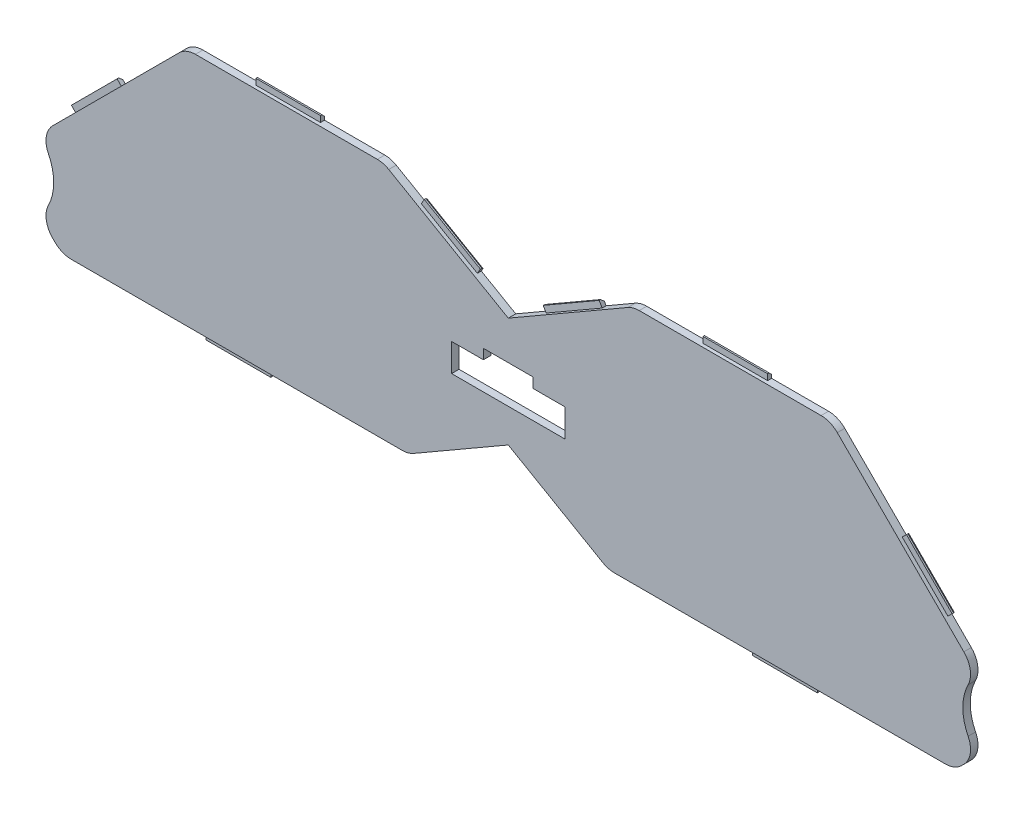
from build123d import *

# Parameters (mm, degrees)
BOSS_EXTRUDE1_DEPTH      = 1.5
SKETCH5_W                = 13
SKETCH5_H                = 1.2
BOSS_EXTRUDE2_DEPTH      = 0.8
CHAMFER1_SIZE            = 0.5
SKETCH6_R                = 10
CUT_EXTRUDE3_DEPTH       = 1.5
CHAMFER1_OF_MIRROR1_SIZE = 0.5
CUT_EXTRUDE1_REACH       = 3.5
FILLET1_R                = 4.6


with BuildPart() as part:
    # Sketch1 → Boss-Extrude1 (new body)
    with BuildSketch(Plane.XY):
        Polygon((0, 22.557357671), (25.107179677, 37.052994616), (64.834314575, 37.052994616), (101.434314575, 0.452994616), (89.834314575, -11.147005384), (20.107179677, -11.147005384), (0, 0.461880215), align=None)
    boss_extrude1 = extrude(amount=BOSS_EXTRUDE1_DEPTH)

    # Sketch5 → Boss-Extrude2 (add)
    with BuildSketch(Plane(origin=(0, 0, 0), x_dir=(-1, 0, 0), z_dir=(0, 0, -1))):
        with Locations((-44.970747126, 37.652994616)):
            Rectangle(SKETCH5_W, SKETCH5_H)
        with Locations((-54.970747126, -11.747005384)):
            Rectangle(SKETCH5_W, SKETCH5_H)
        Polygon((-78.538120497, 23.349188694), (-87.730508653, 14.156800538), (-88.57903679, 15.005328676), (-79.386648635, 24.197716831), align=None)
        Polygon((-18.182754963, 33.055176144), (-6.924424714, 26.555176144), (-6.324424714, 27.594406628), (-17.582754963, 34.094406628), align=None)
    boss_extrude2 = extrude(amount=-BOSS_EXTRUDE2_DEPTH)

    # Chamfer1
    chamfer1_edges = [part.edges().sort_by_distance(p)[0] for p in [
        (44.970747126, 38.252994616, 0),
        (54.970747126, -12.347005384, 0),
        (83.982842712, 19.601522754, 0),
        (11.953589838, 30.844406628, 0),
    ]]
    chamfer(chamfer1_edges, length=CHAMFER1_SIZE)

    # Sketch6 → Cut-Extrude3 (cut)
    with BuildSketch(Plane.XY.offset(1.5)):
        with Locations((101.434314575, 0.452994616)):
            Circle(SKETCH6_R)
    cut_extrude3 = extrude(amount=-CUT_EXTRUDE3_DEPTH, mode=Mode.SUBTRACT)

    # Mirror1: Boss-Extrude1, Boss-Extrude2, Cut-Extrude3 across plane
    add(boss_extrude1.mirror(Plane(origin=(0, 0.461880215, 1.5), x_dir=(0, 0, 1), z_dir=(1, 0, 0))))
    add(boss_extrude2.mirror(Plane(origin=(0, 0.461880215, 1.5), x_dir=(0, 0, 1), z_dir=(1, 0, 0))))
    add(cut_extrude3.mirror(Plane(origin=(0, 0.461880215, 1.5), x_dir=(0, 0, 1), z_dir=(1, 0, 0))), mode=Mode.SUBTRACT)

    # Chamfer1 of Mirror1
    chamfer1_of_mirror1_edges = [part.edges().sort_by_distance(p)[0] for p in [
        (-44.970747126, 38.252994616, 0),
        (-54.970747126, -12.347005384, 0),
        (-83.982842712, 19.601522754, 0),
        (-11.953589838, 30.844406628, 0),
    ]]
    chamfer(chamfer1_of_mirror1_edges, length=CHAMFER1_OF_MIRROR1_SIZE)

    # Sketch2 → Cut-Extrude1 (cut, up to next)
    with BuildSketch(Plane.XY.offset(1.5), mode=Mode.PRIVATE) as cut_extrude1_sk1:
        Polygon((11.4, 7.2), (-11.4, 7.2), (-11.4, 12.8), (-5, 12.8), (-5, 14.8), (5, 14.8), (5, 12.8), (11.4, 12.8), align=None)
    cut_extrude1_tool1 = extrude(cut_extrude1_sk1.sketch, amount=-CUT_EXTRUDE1_REACH, mode=Mode.PRIVATE) & part.part
    add(cut_extrude1_tool1.solids().sort_by_distance((0, 10.514626, 1.5))[0], mode=Mode.SUBTRACT)

    # Fillet1
    fillet1_edges = [part.edges().sort_by_distance(p)[0] for p in [
        (94.363246763, 7.524062428, 0.75),
        (-25.107179677, 37.052994616, 0.75),
        (-64.834314575, 37.052994616, 0.75),
        (-89.834314575, -11.147005384, 0.75),
        (-20.107179677, -11.147005384, 0.75),
        (64.834314575, 37.052994616, 0.75),
        (89.834314575, -11.147005384, 0.75),
        (20.107179677, -11.147005384, 0.75),
        (25.107179677, 37.052994616, 0.75),
        (-94.363246763, 7.524062428, 0.75),
        (-94.363246763, -6.618073196, 0.75),
        (94.363246763, -6.618073196, 0.75),
    ]]
    fillet(fillet1_edges, radius=FILLET1_R)


solid = part.part
